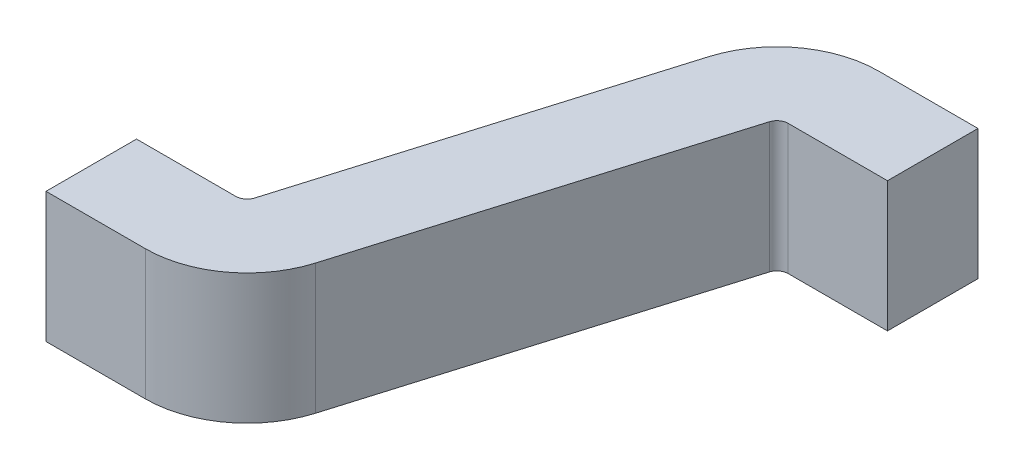
from build123d import *

# Parameters (mm, degrees)
BOSS_EXTRUDE1_DEPTH = 0.23


with BuildPart() as part:
    # Sketch1 → Boss-Extrude1 (new body, symmetric)
    with BuildSketch(Plane(origin=(0, 0, 0), x_dir=(1, 0, 0), z_dir=(0, 1, 0))):
        with BuildLine():
            Line((0, -0.16), (0.351100062, -0.16))
            ThreePointArc((0.351100062, -0.16), (0.566082222, -0.088760577), (0.69597991, 0.09676294))
            Line((0.69597991, 0.09676294), (1.065579955, 1.331470784))
            ThreePointArc((1.065579955, 1.331470784), (1.080013032, 1.352084509), (1.103899938, 1.36))
            Line((1.103899938, 1.36), (1.455, 1.36))
            Line((1.455, 1.36), (1.455, 1.68))
            Line((1.455, 1.68), (1.103899938, 1.68))
            ThreePointArc((1.103899938, 1.68), (0.888917778, 1.608760577), (0.75902009, 1.42323706))
            Line((0.75902009, 1.42323706), (0.389420045, 0.188529216))
            ThreePointArc((0.389420045, 0.188529216), (0.374986968, 0.167915491), (0.351100062, 0.16))
            Line((0.351100062, 0.16), (0, 0.16))
            Line((0, 0.16), (0, -0.16))
        make_face()
    extrude(amount=BOSS_EXTRUDE1_DEPTH, both=True)


solid = part.part
